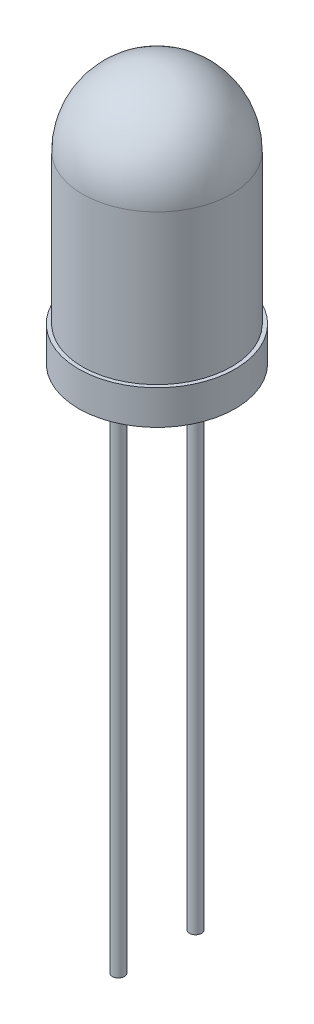
from build123d import *

# Parameters (mm, degrees)
SKETCH1_R           = 2.575
BOSS_EXTRUDE1_DEPTH = 8.5
SKETCH2_R           = 2.575
SKETCH2_R_2         = 2.45
CUT_EXTRUDE1_DEPTH  = 7.37
FILLET2_R           = 2.45
SKETCH4_R           = 0.2
BOSS_EXTRUDE4_DEPTH = 18
SKETCH6_R           = 0.225
CUT_EXTRUDE2_DEPTH  = 2.5


with BuildPart() as part:
    # Sketch1 → Boss-Extrude1 (new body)
    with BuildSketch(Plane(origin=(0, 0, 0), x_dir=(1, 0, 0), z_dir=(0, 1, 0))):
        Circle(SKETCH1_R)
    extrude(amount=BOSS_EXTRUDE1_DEPTH)

    # Sketch2 → Cut-Extrude1 (cut)
    with BuildSketch(Plane(origin=(0, 8.5, 0), x_dir=(1, 0, 0), z_dir=(0, 1, 0))):
        Circle(SKETCH2_R)
        Circle(SKETCH2_R_2, mode=Mode.SUBTRACT)
    extrude(amount=-CUT_EXTRUDE1_DEPTH, mode=Mode.SUBTRACT)

    # Fillet2
    fillet2_edges = [part.edges().sort_by_distance(p)[0] for p in [
        (-2.45, 8.5, 0),
    ]]
    fillet(fillet2_edges, radius=FILLET2_R)

    # Sketch4 → Boss-Extrude4 (add)
    with BuildSketch(Plane(origin=(0, 0, 0), x_dir=(-1, 0, 0), z_dir=(0, -1, 0))):
        with Locations((1.27, 0)):
            Circle(SKETCH4_R)
        with Locations((-1.27, 0)):
            Circle(SKETCH4_R)
    extrude(amount=BOSS_EXTRUDE4_DEPTH)

    # Sketch6 → Cut-Extrude2 (cut)
    with BuildSketch(Plane.XZ.offset(18)):
        with Locations((1.27, 0)):
            Circle(SKETCH6_R)
    extrude(amount=-CUT_EXTRUDE2_DEPTH, mode=Mode.SUBTRACT)


solid = part.part
